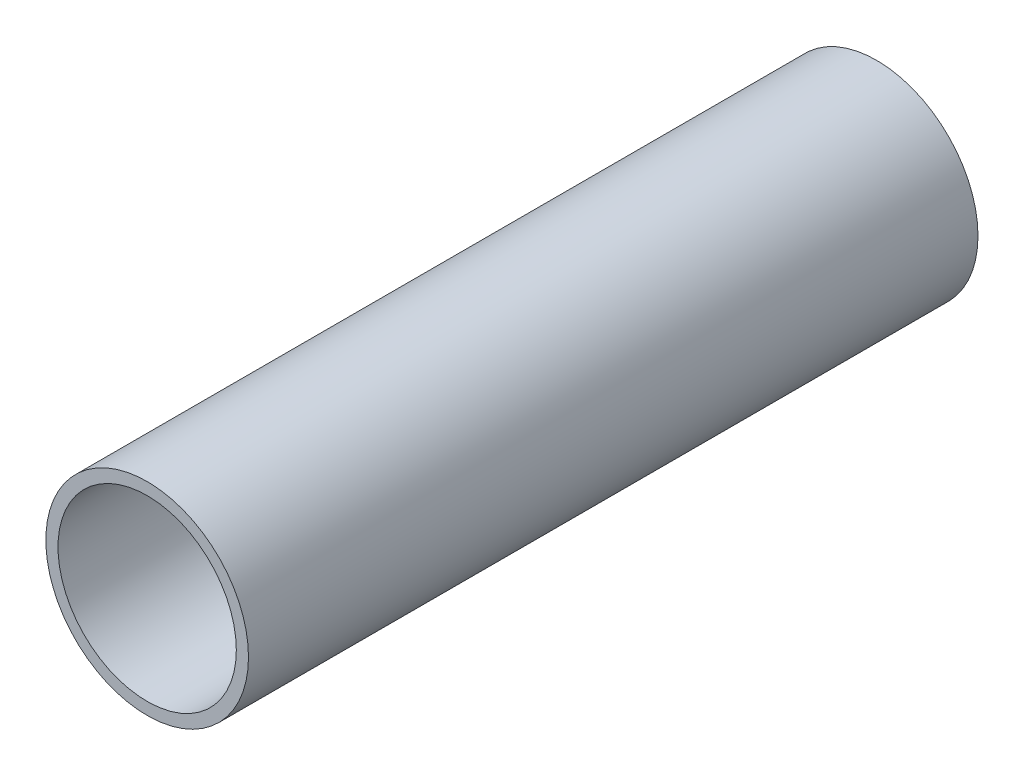
from build123d import *

# Parameters (mm, degrees)
SKETCH1_R           = 12.5
SKETCH1_R_2         = 11
BOSS_EXTRUDE1_DEPTH = 90


with BuildPart() as part:
    # Sketch1 → Boss-Extrude1 (new body)
    with BuildSketch(Plane.XY):
        Circle(SKETCH1_R)
        Circle(SKETCH1_R_2, mode=Mode.SUBTRACT)
    extrude(amount=BOSS_EXTRUDE1_DEPTH)


solid = part.part
